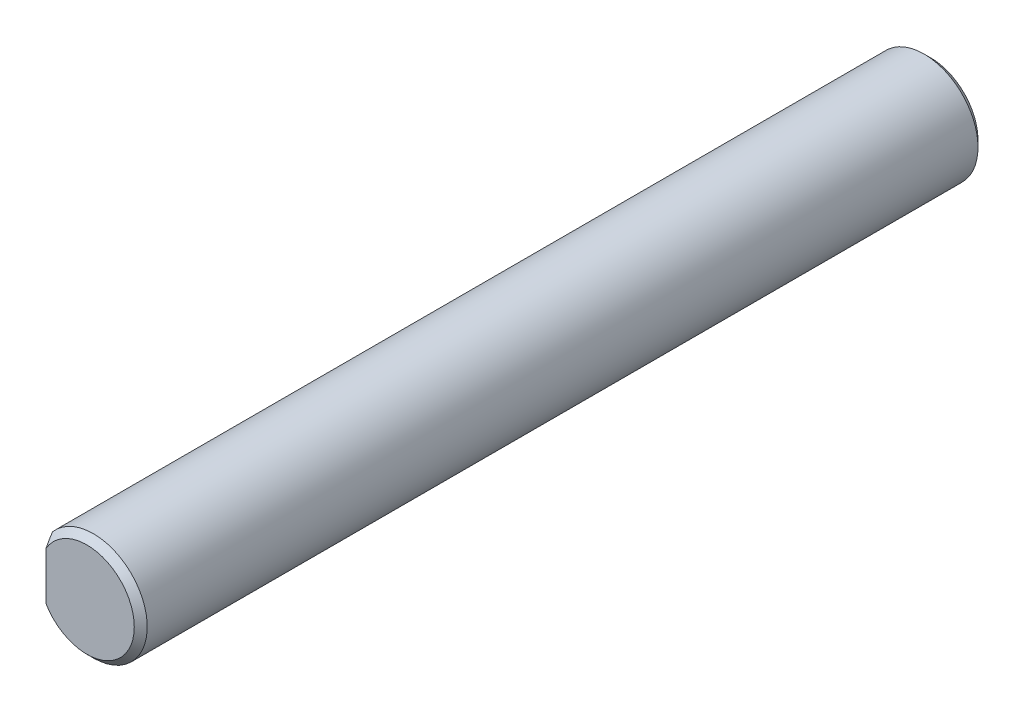
from build123d import *

# Parameters (mm, degrees)
SKETCH1_R           = 4.15
BOSS_EXTRUDE1_DEPTH = 65
CHAMFER1_SIZE       = 0.5
SKETCH2_W           = 1.287128146
SKETCH2_H           = 7.63924008
CUT_EXTRUDE1_DEPTH  = 33


with BuildPart() as part:
    # Sketch1 → Boss-Extrude1 (new body)
    with BuildSketch(Plane.XY):
        Circle(SKETCH1_R)
    extrude(amount=BOSS_EXTRUDE1_DEPTH)

    # Chamfer1
    chamfer1_edges = [part.edges().sort_by_distance(p)[0] for p in [
        (-4.15, 0, 0),
        (-4.15, 0, 65),
    ]]
    chamfer(chamfer1_edges, length=CHAMFER1_SIZE)

    # Sketch2 → Cut-Extrude1 (cut, symmetric)
    with BuildSketch(Plane.XY.offset(32.5)):
        with Locations((-3.793564073, 0)):
            Rectangle(SKETCH2_W, SKETCH2_H)
    extrude(amount=CUT_EXTRUDE1_DEPTH, both=True, mode=Mode.SUBTRACT)


solid = part.part
